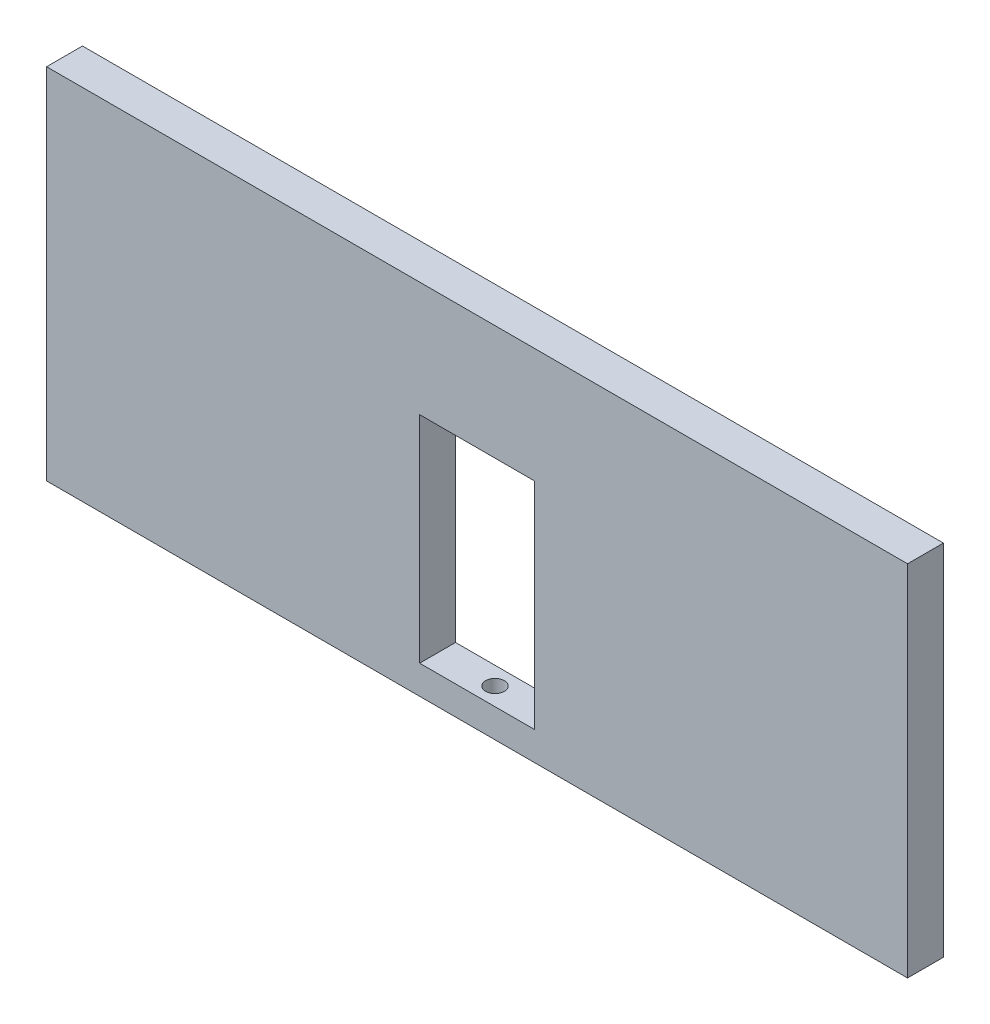
from build123d import *

# Parameters (mm, degrees)
CROQUIS1_W              = 600
CROQUIS1_H              = 250
CROQUIS1_W_2            = 80
CROQUIS1_H_2            = 150
SALIENTE_EXTRUIR2_DEPTH = 25
CORTAR_EXTRUIR2_REACH   = 252
CROQUIS3_R              = 6.5


with BuildPart() as part:
    # Croquis1 → Saliente-Extruir2 (new body)
    with BuildSketch(Plane.XY):
        Rectangle(CROQUIS1_W, CROQUIS1_H)
        with Locations((0, -30)):
            Rectangle(CROQUIS1_W_2, CROQUIS1_H_2, mode=Mode.SUBTRACT)
    extrude(amount=SALIENTE_EXTRUIR2_DEPTH)

    # Croquis3 → Cortar-Extruir2 (cut, up to next)
    with BuildSketch(Plane.XZ.offset(125), mode=Mode.PRIVATE) as cortar_extruir2_sk1:
        with Locations((0, 12.5)):
            Circle(CROQUIS3_R)
    cortar_extruir2_tool1 = extrude(cortar_extruir2_sk1.sketch, amount=-CORTAR_EXTRUIR2_REACH, mode=Mode.PRIVATE) & part.part
    add(cortar_extruir2_tool1.solids().sort_by_distance((0, -125, 12.5))[0], mode=Mode.SUBTRACT)


solid = part.part
